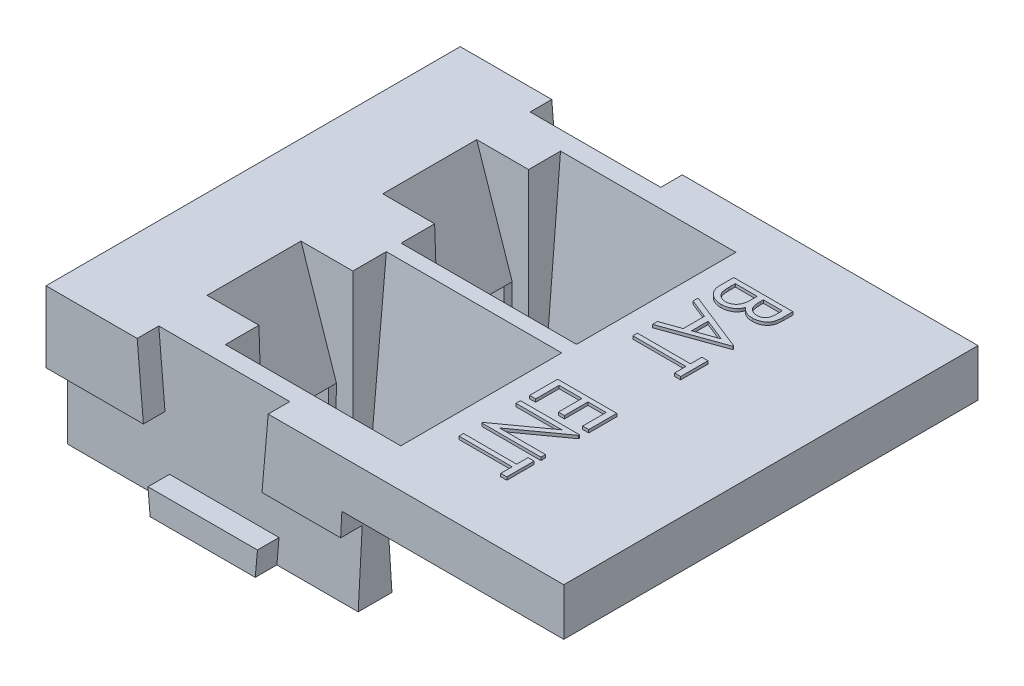
from build123d import *

# Parameters (mm, degrees)
BOSS_EXTRUDE1_DEPTH = 8.89
SKETCH2_W           = 7.4168
SKETCH2_H           = 5.4864
CUT_EXTRUDE1_DEPTH  = 7.35
CUT_EXTRUDE2_DEPTH  = 7.4168
CUT_EXTRUDE3_DEPTH  = 0.9271
CUT_EXTRUDE5_DEPTH  = 0.9271
SKETCH5_W           = 4.5593
SKETCH5_H           = 3.175
CUT_EXTRUDE4_DEPTH  = 1.905
CUT_EXTRUDE6_DEPTH  = 1.905
CUT_EXTRUDE7_DEPTH  = 1.905
BOSS_EXTRUDE2_DEPTH = 0.127
DRAFT1_ANGLE        = -1
DRAFT2_ANGLE        = 1
DRAFT4_ANGLE        = 1
BOSS_EXTRUDE3_DEPTH = 1.016
BOSS_EXTRUDE5_DEPTH = 1.143
CIRPATTERN2_COUNT   = 4


with BuildPart() as part:
    # Sketch1 → Boss-Extrude1 (new body, symmetric)
    with BuildSketch(Plane.XY):
        Polygon((0, 0), (0, 6.35), (22.225, 6.35), (22.225, 4.318), (12.7, 4.318), (12.473703209, 0), align=None)
    extrude(amount=BOSS_EXTRUDE1_DEPTH, both=True)

    # Sketch2 → Cut-Extrude1 (cut, through all)
    with BuildSketch(Plane(origin=(0, 6.35, 0), x_dir=(1, 0, 0), z_dir=(0, 1, 0))):
        with Locations((9.8552, 3.7719)):
            Rectangle(SKETCH2_W, SKETCH2_H)
        with Locations((9.8552, -3.7719)):
            Rectangle(SKETCH2_W, SKETCH2_H)
    extrude(amount=-CUT_EXTRUDE1_DEPTH, mode=Mode.SUBTRACT)

    # Sketch3 → Cut-Extrude2 (cut)
    with BuildSketch(Plane(origin=(6.1468, 0, 0), x_dir=(0, 0, -1), z_dir=(1, 0, 0))):
        Polygon((7.159881254, 6.35), (0.3175, 6.35), (1.0287, 0), (6.5151, 0), align=None)
        Polygon((-0.3175, 6.35), (-7.2263, 6.35), (-6.5151, 0), (-1.0287, 0), align=None)
    extrude(amount=CUT_EXTRUDE2_DEPTH, mode=Mode.SUBTRACT)

    # Sketch4 → Cut-Extrude3 (cut)
    with BuildSketch(Plane(origin=(0, 0, -8.89), x_dir=(-1, 0, 0), z_dir=(0, 0, -1))):
        Polygon((-12.680032636, 3.937), (-9.3218, 3.937), (-9.532910145, 6.35), (-3.929089855, 6.35), (-4.1402, 3.937), (0, 3.937), (0, 0), (-4.484642868, 0), (-4.402421022, 0.9398), (-9.062664714, 0.9398), (-8.980442868, 0), (-12.473703209, 0), align=None)
    extrude(amount=-CUT_EXTRUDE3_DEPTH, mode=Mode.SUBTRACT)

    # Sketch7 → Cut-Extrude5 (cut)
    with BuildSketch(Plane.XY.offset(8.89)):
        Polygon((12.646753696, 3.302), (9.271, 3.302), (9.537665446, 6.35), (3.914225232, 6.35), (4.180890679, 3.302), (0, 3.302), (0, 0), (4.469778246, 0), (4.376445339, 1.0668), (9.075445339, 1.0668), (8.982112433, 0), (12.473703209, 0), align=None)
    extrude(amount=-CUT_EXTRUDE5_DEPTH, mode=Mode.SUBTRACT)

    # Sketch5 → Cut-Extrude4 (cut)
    with BuildSketch(Plane(origin=(0, 0, 0), x_dir=(1, 0, 0), z_dir=(0, 1, 0))):
        with Locations((3.86715, 3.7719)):
            Rectangle(SKETCH5_W, SKETCH5_H)
        with Locations((3.86715, -3.7719)):
            Rectangle(SKETCH5_W, SKETCH5_H)
    extrude(amount=CUT_EXTRUDE4_DEPTH, mode=Mode.SUBTRACT)

    # Sketch8 → Cut-Extrude6 (cut, symmetric)
    with BuildSketch(Plane.XY.offset(3.7719)):
        Polygon((3.81, 6.35), (5.4102, 1.905), (5.4102, 0), (8.6868, 0), (8.6868, 6.35), align=None)
    extrude(amount=CUT_EXTRUDE6_DEPTH, both=True, mode=Mode.SUBTRACT)

    # Sketch9 → Cut-Extrude7 (cut, symmetric)
    with BuildSketch(Plane.XY.offset(-3.7719)):
        Polygon((3.81, 6.35), (5.4102, 1.905), (5.4102, 0), (8.6868, 0), (8.6868, 6.35), align=None)
    extrude(amount=CUT_EXTRUDE7_DEPTH, both=True, mode=Mode.SUBTRACT)

    # Sketch11 → Boss-Extrude2 (add)
    with BuildSketch(Plane(origin=(0, 6.35, 0), x_dir=(1, 0, 0), z_dir=(0, 1, 0))):
        with BuildLine():
            Line((17.1196, 6.050741909), (17.1196, 5.629443832))
            add(Edge.make_bspline(
                [(17.1196, 5.629443832), (17.119465587, 5.608914838), (17.119203206, 5.568841373), (17.115414254, 5.51063454), (17.110176887, 5.456068902), (17.101808135, 5.405337809), (17.091859577, 5.358235979), (17.079727309, 5.314625193), (17.065038984, 5.274737673), (17.042045894, 5.226895837), (17.007152185, 5.172495072), (16.956177337, 5.113789871), (16.894288952, 5.06359403), (16.824179302, 5.020454425), (16.747328234, 4.986145367), (16.665255919, 4.961546754), (16.579112787, 4.946511635), (16.520107822, 4.944554523), (16.490196955, 4.943562422)],
                knots=[0, 0, 0, 0, 6.1575e-05, 0.000120197, 0.000174927, 0.000225953, 0.000274355, 0.000319295, 0.000361637, 0.000401691, 0.000478335, 0.000554775, 0.00063393, 0.000716397, 0.000801123, 0.000885631, 0.000972877, 0.001062573, 0.001062573, 0.001062573, 0.001062573], degree=3))
            add(Edge.make_bspline(
                [(16.490196955, 4.943562422), (16.46217093, 4.944353542), (16.407224703, 4.945904566), (16.326687357, 4.957842986), (16.250016094, 4.977590029), (16.177732335, 5.005504631), (16.110590475, 5.041175661), (16.049830845, 5.084558208), (15.995315855, 5.135423265), (15.965093347, 5.174620282), (15.949836378, 5.194407774)],
                knots=[0, 0, 0, 0, 8.4053e-05, 0.000164789, 0.000243649, 0.000321131, 0.000396705, 0.000471114, 0.000544542, 0.0006194, 0.0006194, 0.0006194, 0.0006194], degree=3))
            add(Edge.make_bspline(
                [(15.949836378, 5.194407774), (15.938735826, 5.169938624), (15.917391483, 5.122888896), (15.879709164, 5.058518083), (15.838912384, 5.002940691), (15.794610154, 4.955779902), (15.746196338, 4.91628405), (15.694355639, 4.881002725), (15.637268042, 4.851428502), (15.576077582, 4.825828965), (15.511374796, 4.805582338), (15.443385227, 4.791355419), (15.372901949, 4.78257246), (15.324868433, 4.781356516), (15.300589583, 4.780741909)],
                knots=[0, 0, 0, 0, 8.0568e-05, 0.000154918, 0.000223303, 0.000287011, 0.000348445, 0.000410397, 0.000474808, 0.000540953, 0.000609188, 0.000677846, 0.000749098, 0.000821922, 0.000821922, 0.000821922, 0.000821922], degree=3))
            add(Edge.make_bspline(
                [(15.300589583, 4.780741909), (15.275803534, 4.781355286), (15.227095649, 4.782560654), (15.155538652, 4.79126097), (15.08711746, 4.806074182), (15.021565318, 4.826545631), (14.958629384, 4.852563699), (14.898432099, 4.884476411), (14.841805639, 4.923290183), (14.787935259, 4.966410288), (14.739442835, 5.015270749), (14.696100395, 5.067621735), (14.660264087, 5.124930007), (14.630893335, 5.185884096), (14.607537914, 5.25080142), (14.591722821, 5.319826354), (14.580972823, 5.392678477), (14.580063503, 5.442668572), (14.5796, 5.468149762)],
                knots=[0, 0, 0, 0, 7.435e-05, 0.000146107, 0.000215866, 0.000284101, 0.000351851, 0.000419913, 0.000488075, 0.000557527, 0.000626606, 0.000694233, 0.000761004, 0.000828819, 0.000896896, 0.000967489, 0.001040958, 0.001117341, 0.001117341, 0.001117341, 0.001117341], degree=3))
            Line((14.5796, 5.468149762), (14.5796, 6.050741909))
            Line((14.5796, 6.050741909), (17.1196, 6.050741909))
        make_face()
        with BuildLine():
            Line((16.859087179, 5.855357294), (16.044984615, 5.855357294))
            Line((16.044984615, 5.855357294), (16.044984615, 5.726118512))
            add(Edge.make_bspline(
                [(16.044984615, 5.726118512), (16.045276893, 5.707123294), (16.045843336, 5.670309982), (16.047424609, 5.617152953), (16.051911563, 5.567994651), (16.0565569, 5.522584537), (16.063684294, 5.48097312), (16.072450842, 5.443348044), (16.081661531, 5.409412892), (16.097479837, 5.370409779), (16.12076889, 5.325935472), (16.156980885, 5.27895328), (16.199499107, 5.237042481), (16.249142126, 5.202383766), (16.303239248, 5.173468728), (16.361667784, 5.154175017), (16.422623568, 5.141069564), (16.46434563, 5.139663778), (16.485617628, 5.138947037)],
                knots=[0, 0, 0, 0, 5.6996e-05, 0.00011046, 0.000159476, 0.000205045, 0.000247372, 0.000286005, 0.00032095, 0.000352697, 0.000412109, 0.000470929, 0.000529938, 0.000590507, 0.000651955, 0.00071326, 0.00077453, 0.000838262, 0.000838262, 0.000838262, 0.000838262], degree=3))
            add(Edge.make_bspline(
                [(16.485617628, 5.138947037), (16.499709097, 5.139196052), (16.527311132, 5.139683815), (16.567554432, 5.144785297), (16.60546671, 5.153607028), (16.641243272, 5.165092868), (16.674599087, 5.18041088), (16.705231715, 5.19957753), (16.734036616, 5.221368643), (16.760051319, 5.247115088), (16.783895609, 5.276337703), (16.804096219, 5.309980223), (16.820760396, 5.347731471), (16.835289182, 5.388956329), (16.845466685, 5.434622694), (16.853847597, 5.483828087), (16.858254826, 5.537268752), (16.858802465, 5.574145845), (16.859087179, 5.593318031)],
                knots=[0, 0, 0, 0, 4.2259e-05, 8.2776e-05, 0.000121409, 0.0001589, 0.000195325, 0.000231192, 0.000267117, 0.000303457, 0.000340725, 0.000379993, 0.000420756, 0.000464362, 0.00051089, 0.000560912, 0.000614027, 0.000671543, 0.000671543, 0.000671543, 0.000671543], degree=3))
            Line((16.859087179, 5.593318031), (16.859087179, 5.855357294))
        make_face(mode=Mode.SUBTRACT)
        with BuildLine():
            Line((15.784471795, 5.855357294), (14.840112821, 5.855357294))
            Line((14.840112821, 5.855357294), (14.840112821, 5.581106492))
            add(Edge.make_bspline(
                [(14.840112821, 5.581106492), (14.84038995, 5.561600819), (14.840925071, 5.523936458), (14.842704459, 5.469446402), (14.846600863, 5.418988854), (14.853084382, 5.372578811), (14.859591545, 5.329949689), (14.86906164, 5.291470214), (14.87935528, 5.256982686), (14.895825145, 5.216722737), (14.920966502, 5.171295404), (14.959412991, 5.123014381), (15.004544041, 5.079701332), (15.056851779, 5.043064003), (15.113667801, 5.012955956), (15.174205093, 4.992343527), (15.236496693, 4.978113432), (15.279139547, 4.976791485), (15.300589583, 4.976126524)],
                knots=[0, 0, 0, 0, 5.8522e-05, 0.000113004, 0.00016354, 0.000210243, 0.000253573, 0.000292818, 0.00032903, 0.000361438, 0.000423164, 0.000484035, 0.000545935, 0.000610171, 0.000675032, 0.000738113, 0.000801582, 0.000865822, 0.000865822, 0.000865822, 0.000865822], degree=3))
            add(Edge.make_bspline(
                [(15.300589583, 4.976126524), (15.327160168, 4.977054546), (15.379239324, 4.978873496), (15.454303785, 4.997534561), (15.524248956, 5.026700135), (15.58788984, 5.067759475), (15.644586282, 5.118524314), (15.692049596, 5.179114778), (15.729739933, 5.248493663), (15.746094765, 5.299241734), (15.754451763, 5.325172999)],
                knots=[0, 0, 0, 0, 7.9572e-05, 0.000155964, 0.000230525, 0.000306038, 0.000382055, 0.000457787, 0.000535876, 0.000617472, 0.000617472, 0.000617472, 0.000617472], degree=3))
            add(Edge.make_bspline(
                [(15.754451763, 5.325172999), (15.756958009, 5.335661782), (15.762381317, 5.358358639), (15.768124637, 5.395454372), (15.773240946, 5.43770744), (15.777029236, 5.485252412), (15.7809373, 5.538143339), (15.782457264, 5.596537134), (15.784276146, 5.660300955), (15.784404777, 5.704576864), (15.784471795, 5.727644954)],
                knots=[0, 0, 0, 0, 3.2341e-05, 6.9983e-05, 0.00011252, 0.000160014, 0.000213051, 0.0002716, 0.00033522, 0.00040442, 0.00040442, 0.00040442, 0.00040442], degree=3))
            Line((15.784471795, 5.727644954), (15.784471795, 5.855357294))
        make_face(mode=Mode.SUBTRACT)
        Polygon((17.1196, 3.478177807), (14.5796, 2.566382935), (14.5796, 2.778558415), (15.393702564, 3.07061771), (15.393702564, 3.98088614), (14.5796, 4.303983095), (14.5796, 4.520229089), (17.1196, 3.510741909), align=None)
        Polygon((16.596030288, 3.502600883), (15.654215385, 3.876579249), (15.654215385, 3.164239505), align=None, mode=Mode.SUBTRACT)
        Polygon((16.859087179, 2.403562422), (17.1196, 2.403562422), (17.1196, 1.23125473), (16.859087179, 1.23125473), (16.859087179, 1.719716268), (14.5796, 1.719716268), (14.5796, 1.915100883), (16.859087179, 1.915100883), align=None)
        Polygon((17.1196, -1.508694872), (17.1196, -2.713566667), (16.859087179, -2.713566667), (16.859087179, -1.704079487), (16.077548718, -1.704079487), (16.077548718, -2.713566667), (15.817035897, -2.713566667), (15.817035897, -1.704079487), (14.840112821, -1.704079487), (14.840112821, -2.713566667), (14.5796, -2.713566667), (14.5796, -1.508694872), align=None)
        Polygon((14.5796, -3.104335897), (17.1196, -3.104335897), (17.1196, -3.14554984), (15.140313141, -4.569720513), (17.1196, -4.569720513), (17.1196, -4.765105128), (14.5796, -4.765105128), (14.5796, -4.720838301), (16.553798718, -3.299720513), (14.5796, -3.299720513), align=None)
        Polygon((16.859087179, -5.058182051), (17.1196, -5.058182051), (17.1196, -6.230489744), (16.859087179, -6.230489744), (16.859087179, -5.742028205), (14.5796, -5.742028205), (14.5796, -5.54664359), (16.859087179, -5.54664359), align=None)
    extrude(amount=BOSS_EXTRUDE2_DEPTH)

    # Draft1
    draft1_faces = [part.faces().sort_by_distance(p)[0] for p in [
        (5.389029187, 3.906400588, 1.8669),
        (6.1468, 3.490248227, 1.252346099),
        (5.389029187, 3.906400588, -5.6769),
        (6.1468, 3.468985441, -6.272121007),
        (5.389029187, 3.906400588, -1.8669),
        (6.1468, 3.490248227, -1.252346099),
        (6.1468, 3.490248227, 6.291453901),
        (5.389029187, 3.906400588, 5.6769),
    ]]
    draft(draft1_faces, Plane(origin=(12.473703209, 0, 8.89), x_dir=(0, 0, -1), z_dir=(0, -1, 0)), DRAFT1_ANGLE)

    # Draft2
    draft2_faces = [part.faces().sort_by_distance(p)[0] for p in [
        (13.5636, 5.345536091, 3.7719),
        (13.5636, 5.345090023, -3.743946128),
    ]]
    draft(draft2_faces, Plane(origin=(0, 6.35, 8.89), x_dir=(0, 0, 1), z_dir=(0, 1, 0)), DRAFT2_ANGLE)

    # Draft4
    draft4_faces = [part.faces().sort_by_distance(p)[0] for p in [
        (3.49885, 0.9525, -2.1844),
        (1.5875, 0.9525, -3.7719),
        (3.49885, 0.9525, -5.3594),
        (3.49885, 0.9525, 2.1844),
        (3.49885, 0.9525, 5.3594),
        (1.5875, 0.9525, 3.7719),
    ]]
    draft(draft4_faces, Plane(origin=(0, 1.905, 0), x_dir=(0, 0, -1), z_dir=(0, -1, 0)), DRAFT4_ANGLE)

    # Sketch13 → Cut-Revolve2 (revolve, cut)
    with BuildSketch(Plane.XY):
        Polygon((0, 5.693854798), (1.212882733, 5.6515), (2.54, 5.2959), (2.54, 4.8895), (0.127, 4.847380928), (0.127, 3.175), (0, 3.175), align=None)
    revolve(axis=Axis((0.127, 3.175, 0), (1, 0, 0)), mode=Mode.SUBTRACT)

    # Sketch14 → Boss-Extrude3 (add)
    with BuildSketch(Plane.ZY.offset(-2.54)):
        with BuildLine():
            Line((-1.191814091, 4.98528256), (-1.378396733, 5.308453174))
            Line((-1.378396733, 5.308453174), (-1.15842628, 5.435453174))
            Line((-1.15842628, 5.435453174), (-0.971843639, 5.11228256))
            ThreePointArc((-0.971843639, 5.11228256), (-1.04775, 4.989756234), (-1.191814091, 4.98528256))
        make_face()
    boss_extrude3 = extrude(amount=BOSS_EXTRUDE3_DEPTH)

    # Sketch17 → Boss-Extrude5 (add, along a direction that is not the sketch's normal)
    with BuildSketch(Plane.ZY.offset(-1.524)):
        with BuildLine():
            Line((-1.225843639, 5.552223465), (-1.519137576, 5.552223465))
            Line((-1.519137576, 5.552223465), (-1.191814091, 4.98528256))
            ThreePointArc((-1.191814091, 4.98528256), (-1.04775, 4.989756234), (-0.971843639, 5.11228256))
            Line((-0.971843639, 5.11228256), (-1.225843639, 5.552223465))
        make_face()
    boss_extrude5 = extrude(amount=BOSS_EXTRUDE5_DEPTH, dir=(-0.923069999, 0.333101084, -0.192316001))

    # CirPattern2: Boss-Extrude3, Boss-Extrude5 ×4 about axis
    cirpattern2_axis = Axis((0.127, 3.175, 0), (1, 0, 0))
    for i in range(1, CIRPATTERN2_COUNT):
        add(boss_extrude3.rotate(cirpattern2_axis, i * 360 / CIRPATTERN2_COUNT))
        add(boss_extrude5.rotate(cirpattern2_axis, i * 360 / CIRPATTERN2_COUNT))


solid = part.part
